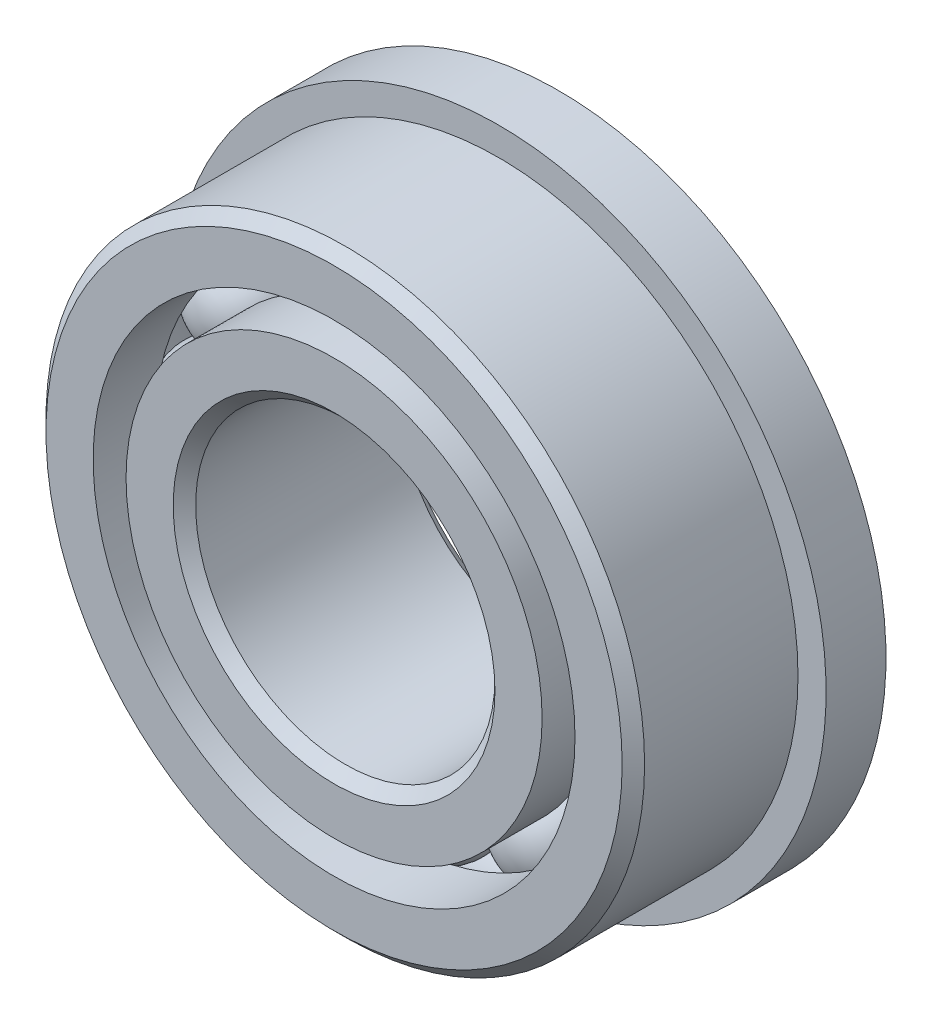
from build123d import *

# Parameters (mm, degrees)
SKETCH5_W         = 1.27
SKETCH5_H         = 1.335261951
CIRPATTERN1_COUNT = 12


with BuildPart() as part:
    # Sketch1 → Revolve1 (revolve)
    with BuildSketch(Plane(origin=(0, 0, 0), x_dir=(0, 0, -1), z_dir=(1, 0, 0))):
        with BuildLine():
            Line((2.143125, 6.35), (-2.143125, 6.35))
            Line((-2.143125, 6.35), (-2.38125, 6.111875))
            Line((-2.38125, 6.111875), (-2.38125, 5.111401099))
            Line((-2.38125, 5.111401099), (-1.058333333, 5.111401099))
            ThreePointArc((-1.058333333, 5.111401099), (0, 5.876861441), (1.058333333, 5.111401099))
            Line((1.058333333, 5.111401099), (2.38125, 5.111401099))
            Line((2.38125, 5.111401099), (2.38125, 6.111875))
            Line((2.38125, 6.111875), (2.143125, 6.35))
        make_face()
    revolve(axis=Axis((0, 0, 2.38125), (0, 0, -1)))

    # Sketch5 → Revolve5 (revolve)
    with BuildSketch(Plane(origin=(0, 0, 0), x_dir=(0, 0, -1), z_dir=(1, 0, 0))):
        with Locations((1.74625, 6.279269025)):
            Rectangle(SKETCH5_W, SKETCH5_H)
    revolve(axis=Axis((0, 0, -2.38125), (0, 0, 1)))


with BuildPart() as body_2:
    # Sketch3 → Revolve3 (revolve)
    with BuildSketch(Plane(origin=(0, 0, 0), x_dir=(0, 0, -1), z_dir=(1, 0, 0))):
        with BuildLine():
            Line((-1.058333333, 4.413598901), (-2.38125, 4.413598901))
            Line((-2.38125, 4.413598901), (-2.38125, 3.413125))
            Line((-2.38125, 3.413125), (-2.143125, 3.175))
            Line((-2.143125, 3.175), (2.143125, 3.175))
            Line((2.143125, 3.175), (2.38125, 3.413125))
            Line((2.38125, 3.413125), (2.38125, 4.413598901))
            Line((2.38125, 4.413598901), (1.058333333, 4.413598901))
            ThreePointArc((1.058333333, 4.413598901), (0, 3.648138559), (-1.058333333, 4.413598901))
        make_face()
    revolve(axis=Axis((0, 0, 2.38125), (0, 0, -1)))


with BuildPart() as body_3:
    # Sketch4 → Revolve4 (revolve)
    with BuildSketch(Plane(origin=(0, 0, 0), x_dir=(0, 0, -1), z_dir=(1, 0, 0))):
        with BuildLine():
            Line((-1.114361441, 4.7625), (1.114361441, 4.7625))
            ThreePointArc((1.114361441, 4.7625), (0, 5.876861441), (-1.114361441, 4.7625))
        make_face()
    revolve(axis=Axis((0, 4.7625, 1.114361441), (0, 0, -1)))


with BuildPart() as cirpattern1_1:
    # CirPattern1: pattern copy
    add(body_3.part.rotate(Axis((0, 0, -2.38125), (0, 0, 1)), 1 * 360 / CIRPATTERN1_COUNT))


with BuildPart() as cirpattern1_2:
    # CirPattern1: pattern copy
    add(body_3.part.rotate(Axis((0, 0, -2.38125), (0, 0, 1)), 2 * 360 / CIRPATTERN1_COUNT))


with BuildPart() as cirpattern1_3:
    # CirPattern1: pattern copy
    add(body_3.part.rotate(Axis((0, 0, -2.38125), (0, 0, 1)), 3 * 360 / CIRPATTERN1_COUNT))


with BuildPart() as cirpattern1_4:
    # CirPattern1: pattern copy
    add(body_3.part.rotate(Axis((0, 0, -2.38125), (0, 0, 1)), 4 * 360 / CIRPATTERN1_COUNT))


with BuildPart() as cirpattern1_5:
    # CirPattern1: pattern copy
    add(body_3.part.rotate(Axis((0, 0, -2.38125), (0, 0, 1)), 5 * 360 / CIRPATTERN1_COUNT))


with BuildPart() as cirpattern1_6:
    # CirPattern1: pattern copy
    add(body_3.part.rotate(Axis((0, 0, -2.38125), (0, 0, 1)), 6 * 360 / CIRPATTERN1_COUNT))


with BuildPart() as cirpattern1_7:
    # CirPattern1: pattern copy
    add(body_3.part.rotate(Axis((0, 0, -2.38125), (0, 0, 1)), 7 * 360 / CIRPATTERN1_COUNT))


with BuildPart() as cirpattern1_8:
    # CirPattern1: pattern copy
    add(body_3.part.rotate(Axis((0, 0, -2.38125), (0, 0, 1)), 8 * 360 / CIRPATTERN1_COUNT))


with BuildPart() as cirpattern1_9:
    # CirPattern1: pattern copy
    add(body_3.part.rotate(Axis((0, 0, -2.38125), (0, 0, 1)), 9 * 360 / CIRPATTERN1_COUNT))


with BuildPart() as cirpattern1_10:
    # CirPattern1: pattern copy
    add(body_3.part.rotate(Axis((0, 0, -2.38125), (0, 0, 1)), 10 * 360 / CIRPATTERN1_COUNT))


with BuildPart() as cirpattern1_11:
    # CirPattern1: pattern copy
    add(body_3.part.rotate(Axis((0, 0, -2.38125), (0, 0, 1)), 11 * 360 / CIRPATTERN1_COUNT))


solid = Compound([part.part, body_2.part, body_3.part, cirpattern1_1.part, cirpattern1_2.part, cirpattern1_3.part, cirpattern1_4.part, cirpattern1_5.part, cirpattern1_6.part, cirpattern1_7.part, cirpattern1_8.part, cirpattern1_9.part, cirpattern1_10.part, cirpattern1_11.part])
